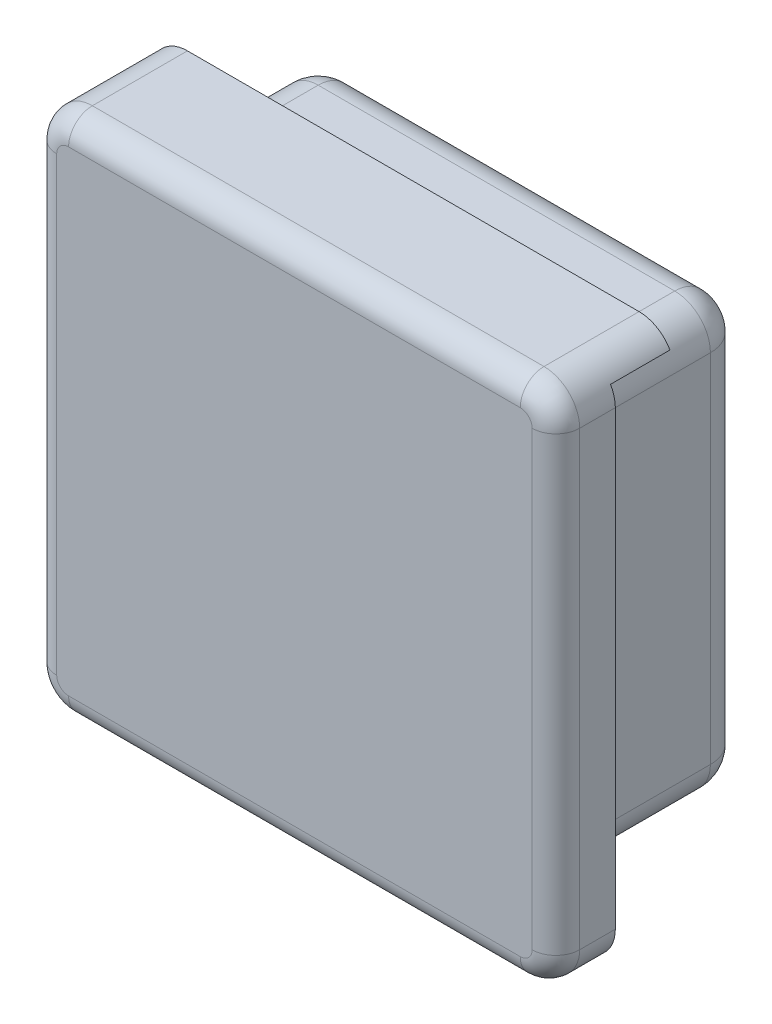
from build123d import *

# Parameters (mm, degrees)
ESQUISSE2_W             = 44
ESQUISSE2_H             = 44
BOSS_EXTRU_1_DEPTH      = 10
ESQUISSE3_W             = 36
ESQUISSE3_H             = 36
BOSS_EXTRU_2_DEPTH      = 10
ESQUISSE4_W             = 42.5
ESQUISSE4_H             = 42.5
ESQUISSE4_W_2           = 36
ESQUISSE4_H_2           = 36
ENL_V_MAT_EXTRU_1_DEPTH = 5
CONG_1_R                = 3
CONG_2_R                = 2


with BuildPart() as part:
    # Esquisse2 → Boss.-Extru.1 (new body)
    with BuildSketch(Plane.XY):
        with Locations((22, 22)):
            Rectangle(ESQUISSE2_W, ESQUISSE2_H)
    extrude(amount=BOSS_EXTRU_1_DEPTH)

    # Esquisse3 → Boss.-Extru.2 (add)
    with BuildSketch(Plane(origin=(0, 0, 0), x_dir=(-1, 0, 0), z_dir=(0, 0, -1))):
        with Locations((-22, 22)):
            Rectangle(ESQUISSE3_W, ESQUISSE3_H)
    extrude(amount=BOSS_EXTRU_2_DEPTH)

    # Esquisse4 → Enlèv. mat.-Extru.1 (cut)
    with BuildSketch(Plane(origin=(0, 0, 0), x_dir=(-1, 0, 0), z_dir=(0, 0, -1))):
        with Locations((-22.75, 21.25)):
            Rectangle(ESQUISSE4_W, ESQUISSE4_H)
        with Locations((-22, 22)):
            Rectangle(ESQUISSE4_W_2, ESQUISSE4_H_2, mode=Mode.SUBTRACT)
    extrude(amount=-ENL_V_MAT_EXTRU_1_DEPTH, mode=Mode.SUBTRACT)

    # Congé1
    cong_1_edges = [part.edges().sort_by_distance(p)[0] for p in [
        (22, 40, -10),
        (4, 22, -10),
        (22, 4, -10),
        (40, 22, -10),
        (44, 0, 7.5),
        (44, 44, 5),
        (0, 0, 5),
        (0, 44, 5),
        (1.5, 42.5, 2.5),
        (4, 4, -2.5),
        (4, 40, -2.5),
        (40, 4, -2.5),
        (40, 40, -2.5),
    ]]
    fillet(cong_1_edges, radius=CONG_1_R)

    # Congé2
    cong_2_edges = [part.edges().sort_by_distance(p)[0] for p in [
        (44, 22, 10),
        (22, 0, 10),
        (0, 22, 10),
        (22, 44, 10),
        (0.878679656, 43.121320344, 10),
        (0.878679656, 0.878679656, 10),
        (43.121320344, 43.121320344, 10),
        (43.121320344, 0.878679656, 10),
    ]]
    fillet(cong_2_edges, radius=CONG_2_R)


solid = part.part
